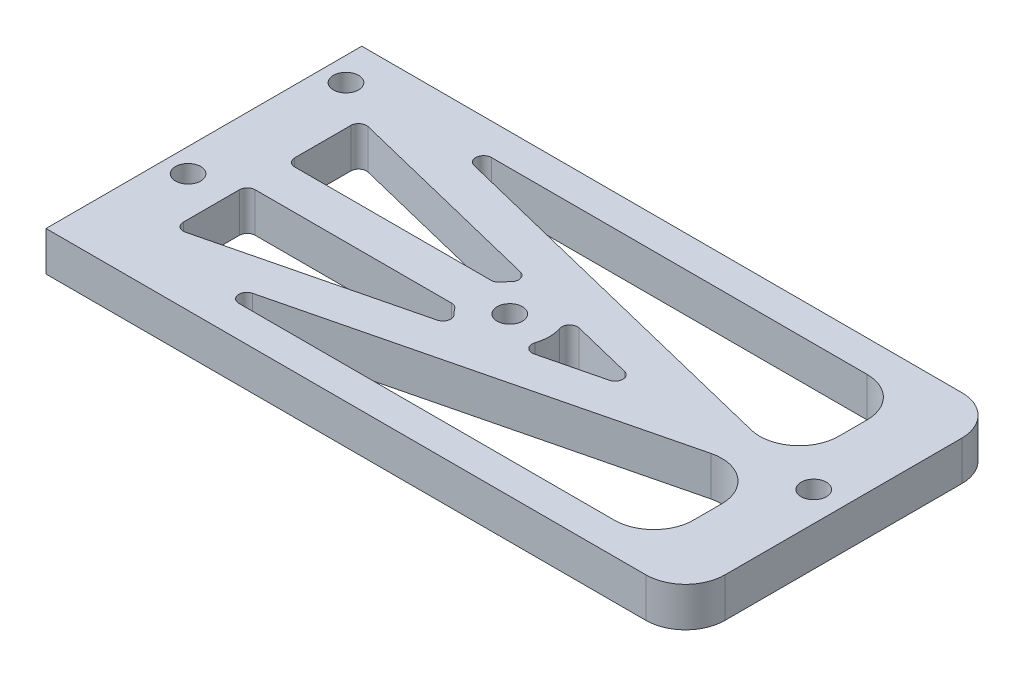
from build123d import *

# Parameters (mm, degrees)
SKETCH_1_W          = 81
SKETCH_1_H          = 40
EXTRUDE_1_DEPTH     = 5
SKETCH_2_R          = 1.6
CUT_EXTRUDE_1_DEPTH = 6
FILLET_1_R          = 5
SKETCH_3_R          = 1.6
CUT_EXTRUDE_2_DEPTH = 6
CUT_EXTRUDE_5_DEPTH = 10
FILLET_2_R          = 5
FILLET_3_R          = 5
FILLET_4_R          = 1
FILLET_5_R          = 1


with BuildPart() as part:
    # 草图1 → 凸台-拉伸1 (new body)
    with BuildSketch(Plane(origin=(0, 0, 0), x_dir=(1, 0, 0), z_dir=(0, 1, 0))):
        Rectangle(SKETCH_1_W, SKETCH_1_H)
    extrude(amount=EXTRUDE_1_DEPTH)

    # 草图2 → 切除-拉伸1 (cut, through all)
    with BuildSketch(Plane.XZ):
        with Locations((36.75, 0)):
            Circle(SKETCH_2_R)
        with Locations((-1.75, 0)):
            Circle(SKETCH_2_R)
    extrude(amount=-CUT_EXTRUDE_1_DEPTH, mode=Mode.SUBTRACT)

    # 圆角1
    fillet_1_edges = [part.edges().sort_by_distance(p)[0] for p in [
        (40.5, 2.5, 20),
        (40.5, 2.5, -20),
    ]]
    fillet(fillet_1_edges, radius=FILLET_1_R)

    # 草图3 → 切除-拉伸2 (cut, through all)
    with BuildSketch(Plane.XZ):
        with Locations((-37.5, 5)):
            Circle(SKETCH_3_R)
        with Locations((-37.5, -15)):
            Circle(SKETCH_3_R)
    extrude(amount=-CUT_EXTRUDE_2_DEPTH, mode=Mode.SUBTRACT)

    # 草图4 → 切除-拉伸5 (cut)
    with BuildSketch(Plane.XZ):
        Polygon((32.5, 16), (-28.316233007, 16), (32.5, 1.029850337), align=None)
        with BuildLine():
            Line((-3.40399678, 4.718505553), (-32.5, 11.880598653))
            Line((-32.5, 11.880598653), (-32.5, 2.5))
            Line((-32.5, 2.5), (-6.080127019, 2.5))
            ThreePointArc((-6.080127019, 2.5), (-4.941061913, 3.849301738), (-3.40399678, 4.718505553))
        make_face()
        Polygon((32.5, -1.029850337), (-28.316233007, -16), (32.5, -16), align=None)
        with BuildLine():
            Line((15.764932029, 0), (1.905256588, 3.411612416))
            ThreePointArc((1.905256588, 3.411612416), (3.25, 0), (1.905256588, -3.411612416))
            Line((1.905256588, -3.411612416), (15.764932029, 0))
        make_face()
        with BuildLine():
            Line((-32.5, -2.5), (-32.5, -11.880598653))
            Line((-32.5, -11.880598653), (-3.40399678, -4.718505553))
            ThreePointArc((-3.40399678, -4.718505553), (-4.941061913, -3.849301738), (-6.080127019, -2.5))
            Line((-6.080127019, -2.5), (-32.5, -2.5))
        make_face()
    extrude(amount=-CUT_EXTRUDE_5_DEPTH, mode=Mode.SUBTRACT)

    # 圆角2
    fillet_2_edges = [part.edges().sort_by_distance(p)[0] for p in [
        (32.5, 2.5, 1.029850337),
        (32.5, 2.5, -1.029850337),
    ]]
    fillet(fillet_2_edges, radius=FILLET_2_R)

    # 圆角3
    fillet_3_edges = [part.edges().sort_by_distance(p)[0] for p in [
        (32.5, 2.5, 16),
        (32.5, 2.5, -16),
    ]]
    fillet(fillet_3_edges, radius=FILLET_3_R)

    # 圆角4
    fillet_4_edges = [part.edges().sort_by_distance(p)[0] for p in [
        (1.905256588, 2.5, -3.411612416),
        (1.905256588, 2.5, 3.411612416),
        (15.764932029, 2.5, 0),
    ]]
    fillet(fillet_4_edges, radius=FILLET_4_R)

    # 圆角5
    fillet_5_edges = [part.edges().sort_by_distance(p)[0] for p in [
        (-6.080127019, 2.5, -2.5),
        (-3.40399678, 2.5, -4.718505553),
        (-32.5, 2.5, -11.880598653),
        (-32.5, 2.5, -2.5),
        (-28.316233007, 2.5, 16),
        (-28.316233007, 2.5, -16),
        (-3.40399678, 2.5, 4.718505553),
        (-6.080127019, 2.5, 2.5),
        (-32.5, 2.5, 2.5),
        (-32.5, 2.5, 11.880598653),
    ]]
    fillet(fillet_5_edges, radius=FILLET_5_R)


solid = part.part
